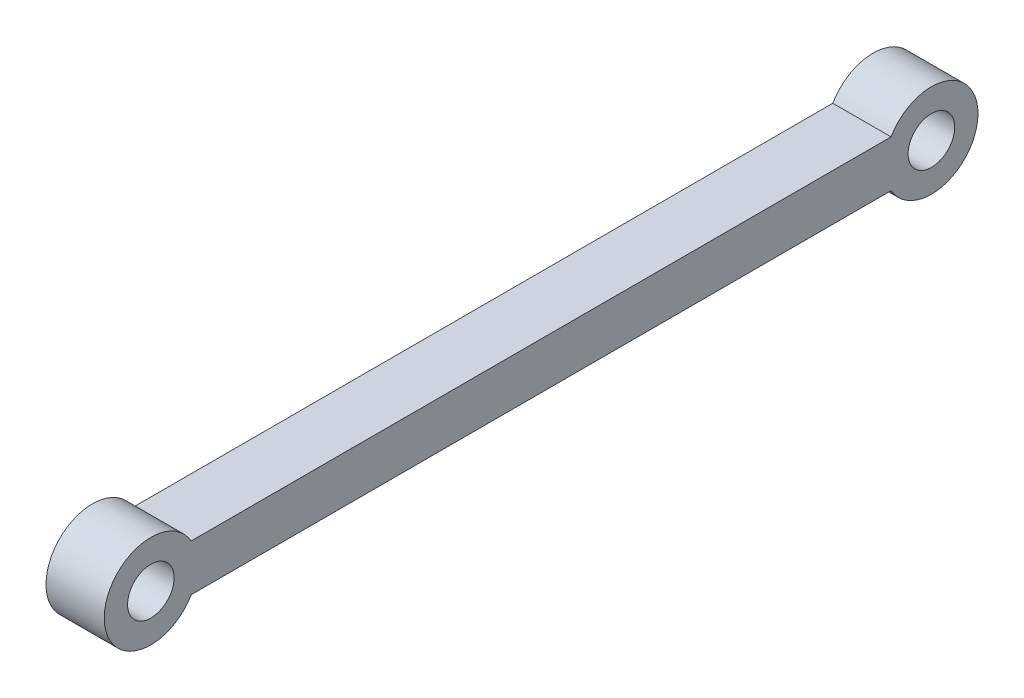
from build123d import *

# Parameters (mm, degrees)
SKETCH1_R           = 1
BOSS_EXTRUDE1_DEPTH = 1.25


with BuildPart() as part:
    # Sketch1 → Boss-Extrude1 (new body, symmetric)
    with BuildSketch(Plane(origin=(0, 0, 0), x_dir=(0, 0, -1), z_dir=(1, 0, 0))):
        with BuildLine():
            Line((-15.017949192, -2), (15.017949192, -2))
            ThreePointArc((15.017949192, -2), (18.75, -1), (15.017949192, 0))
            Line((15.017949192, 0), (-15.017949192, 0))
            ThreePointArc((-15.017949192, 0), (-18.75, -1), (-15.017949192, -2))
        make_face()
        with Locations((-16.75, -1)):
            Circle(SKETCH1_R, mode=Mode.SUBTRACT)
        with Locations((16.75, -1)):
            Circle(SKETCH1_R, mode=Mode.SUBTRACT)
    extrude(amount=BOSS_EXTRUDE1_DEPTH, both=True)


solid = part.part
